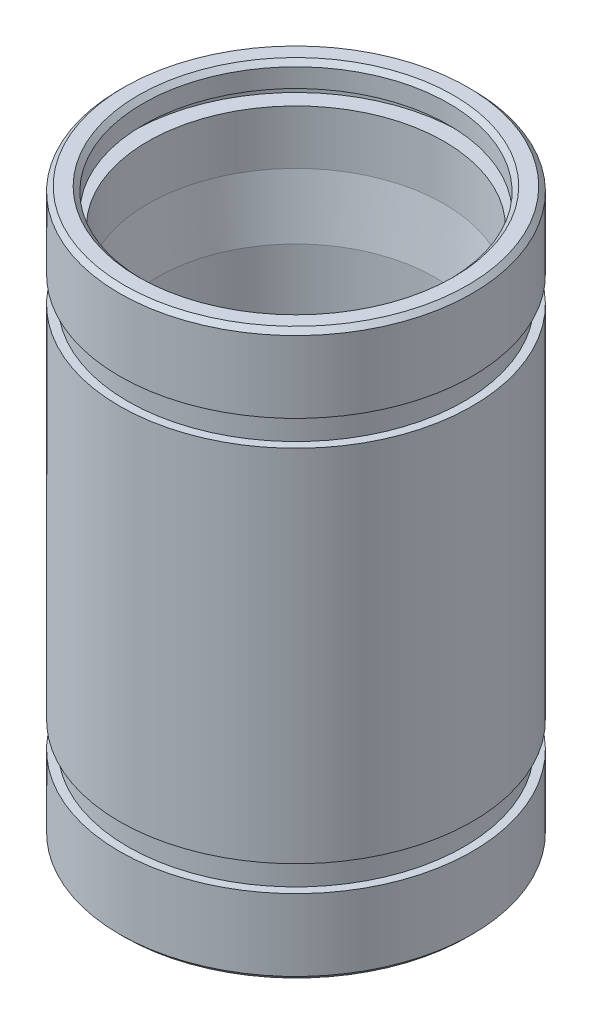
from build123d import *


with BuildPart() as part:
    # Sketch1 → Revolve1 (revolve)
    with BuildSketch(Plane(origin=(0, 0, 0), x_dir=(0, 0, -1), z_dir=(1, 0, 0))):
        Polygon((6.7, 12), (7.3, 12), (7.5, 11.8), (7.5, 8.75), (7.15, 8.75), (7.15, 7.65), (7.5, 7.65), (7.5, -7.65), (7.15, -7.65), (7.15, -8.75), (7.5, -8.75), (7.5, -11.8), (7.3, -12), (6.7, -12), (6.5, -11.8), (6.5, -11), (7, -11), (7, -10.5), (6.3, -10.5), (6.3, -8.2), (5.9, -5.7), (5.9, 5.7), (6.3, 8.2), (6.3, 10.5), (7, 10.5), (7, 11), (6.5, 11), (6.5, 11.8), align=None)
    revolve(axis=Axis((0, 12, 0), (0, -1, 0)))


solid = part.part
